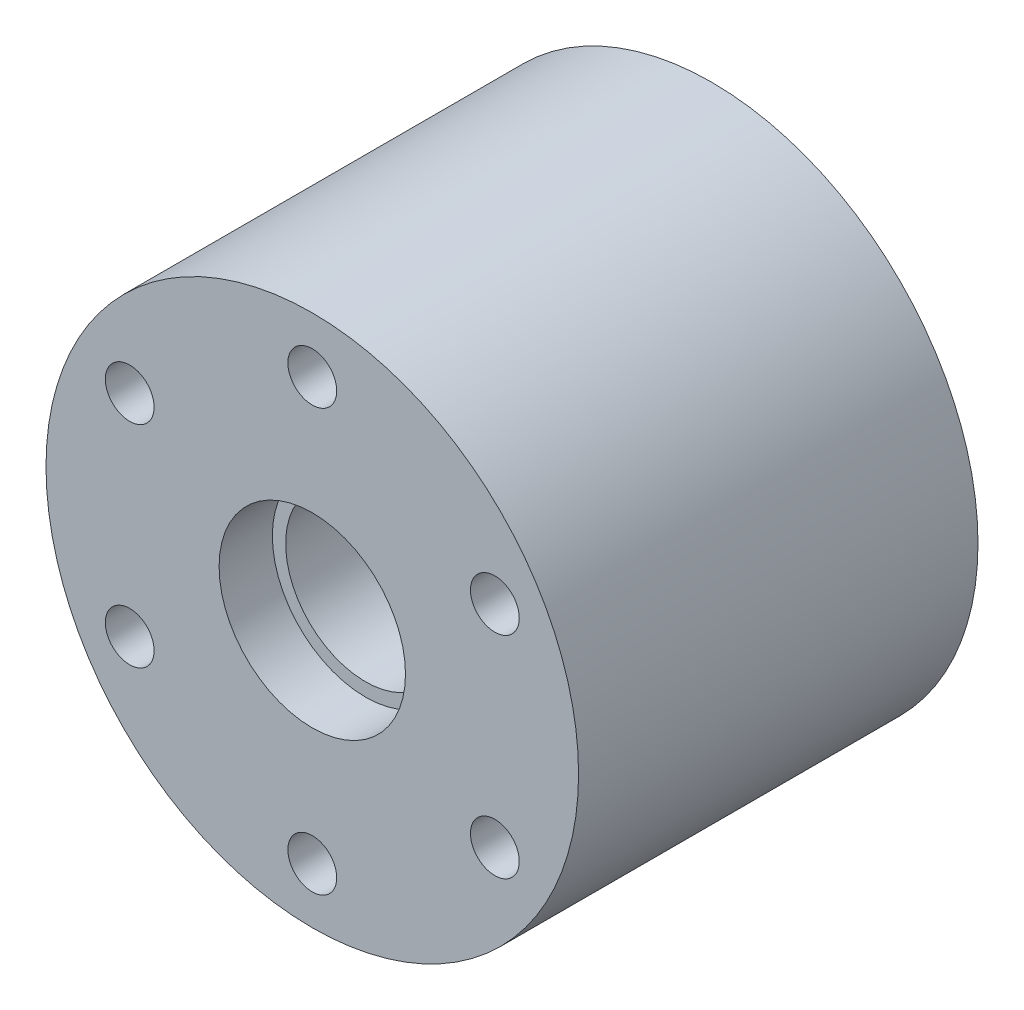
from build123d import *

# Parameters (mm, degrees)
SKETCH1_R            = 30
SKETCH1_R_2          = 9
BOSS_EXTRUDE1_DEPTH  = 45
M5_CLEARANCE_HOLE1_D = 5.5
SKETCH4_R            = 10.5
CUT_EXTRUDE1_DEPTH   = 6


with BuildPart() as part:
    # Sketch1 → Boss-Extrude1 (new body)
    with BuildSketch(Plane.XY):
        Circle(SKETCH1_R)
        Circle(SKETCH1_R_2, mode=Mode.SUBTRACT)
    extrude(amount=BOSS_EXTRUDE1_DEPTH)

    # M5 Clearance Hole1 (through all)
    with Locations(Plane.XY.offset(45)):
        with Locations((0, 23.75), (20.56810334, 11.875), (20.56810334, -11.875), (0, -23.75), (-20.56810334, -11.875), (-20.56810334, 11.875), (0, 0)):
            Hole(M5_CLEARANCE_HOLE1_D / 2)

    # Sketch4 → Cut-Extrude1 (cut)
    with BuildSketch(Plane.XY.offset(45)):
        Circle(SKETCH4_R)
    extrude(amount=-CUT_EXTRUDE1_DEPTH, mode=Mode.SUBTRACT)


solid = part.part
